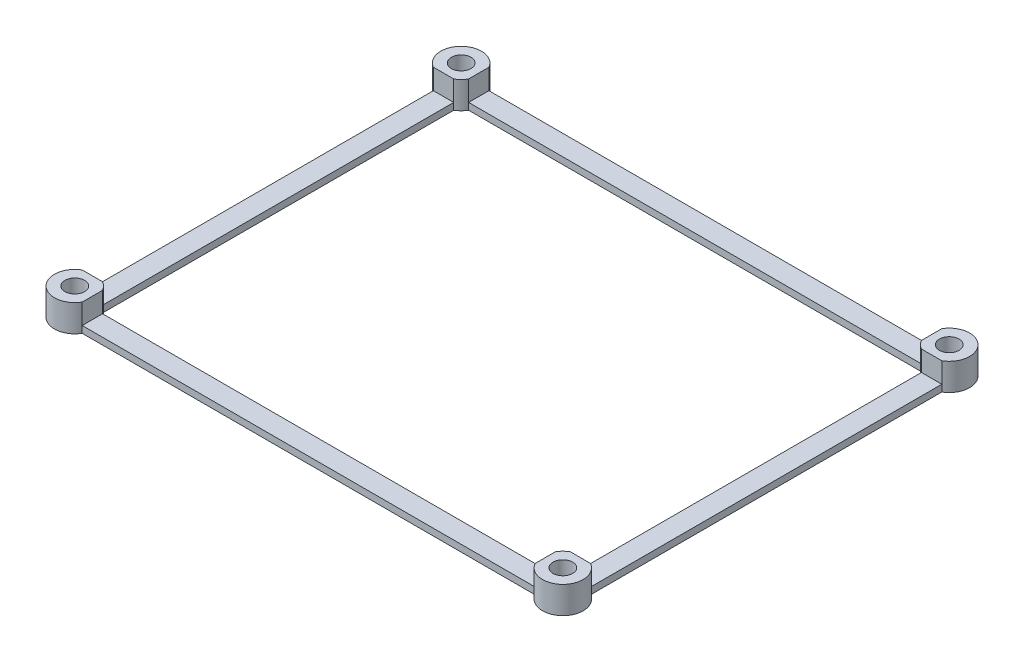
from build123d import *

# Parameters (mm, degrees)
SKETCH1_R           = 1.45
BOSS_EXTRUDE1_DEPTH = 4
SKETCH2_W           = 3
SKETCH2_H           = 51.803847578
SKETCH2_W_2         = 66.803847578
SKETCH2_H_2         = 3
CUT_EXTRUDE1_DEPTH  = 3


with BuildPart() as part:
    # Sketch1 → Boss-Extrude1 (new body)
    with BuildSketch(Plane(origin=(0, 0, 0), x_dir=(1, 0, 0), z_dir=(0, 1, 0))):
        with BuildLine():
            Line((-33.401923789, 30), (33.401923789, 30))
            ThreePointArc((33.401923789, 30), (38.121320344, 30.621320344), (37.5, 25.901923789))
            Line((37.5, 25.901923789), (37.5, -25.901923789))
            ThreePointArc((37.5, -25.901923789), (38.121320344, -30.621320344), (33.401923789, -30))
            Line((33.401923789, -30), (-33.401923789, -30))
            ThreePointArc((-33.401923789, -30), (-38.121320344, -30.621320344), (-37.5, -25.901923789))
            Line((-37.5, -25.901923789), (-37.5, 25.901923789))
            ThreePointArc((-37.5, 25.901923789), (-38.121320344, 30.621320344), (-33.401923789, 30))
        make_face()
        with Locations((36, 28.5)):
            Circle(SKETCH1_R, mode=Mode.SUBTRACT)
        with Locations((36, -28.5)):
            Circle(SKETCH1_R, mode=Mode.SUBTRACT)
        with Locations((-36, -28.5)):
            Circle(SKETCH1_R, mode=Mode.SUBTRACT)
        with Locations((-36, 28.5)):
            Circle(SKETCH1_R, mode=Mode.SUBTRACT)
        with BuildLine():
            Line((-33.401923789, 27), (33.401923789, 27))
            ThreePointArc((33.401923789, 27), (33.878679656, 26.378679656), (34.5, 25.901923789))
            Line((34.5, 25.901923789), (34.5, -25.901923789))
            ThreePointArc((34.5, -25.901923789), (33.878679656, -26.378679656), (33.401923789, -27))
            Line((33.401923789, -27), (-33.401923789, -27))
            ThreePointArc((-33.401923789, -27), (-33.878679656, -26.378679656), (-34.5, -25.901923789))
            Line((-34.5, -25.901923789), (-34.5, 25.901923789))
            ThreePointArc((-34.5, 25.901923789), (-33.878679656, 26.378679656), (-33.401923789, 27))
        make_face(mode=Mode.SUBTRACT)
    extrude(amount=BOSS_EXTRUDE1_DEPTH)

    # Sketch2 → Cut-Extrude1 (cut)
    with BuildSketch(Plane(origin=(0, 4, 0), x_dir=(1, 0, 0), z_dir=(0, 1, 0))):
        with Locations((-36, 0)):
            Rectangle(SKETCH2_W, SKETCH2_H)
        with Locations((0, -28.5)):
            Rectangle(SKETCH2_W_2, SKETCH2_H_2)
        with Locations((36, 0)):
            Rectangle(SKETCH2_W, SKETCH2_H)
        with Locations((0, 28.5)):
            Rectangle(SKETCH2_W_2, SKETCH2_H_2)
    extrude(amount=-CUT_EXTRUDE1_DEPTH, mode=Mode.SUBTRACT)


solid = part.part
